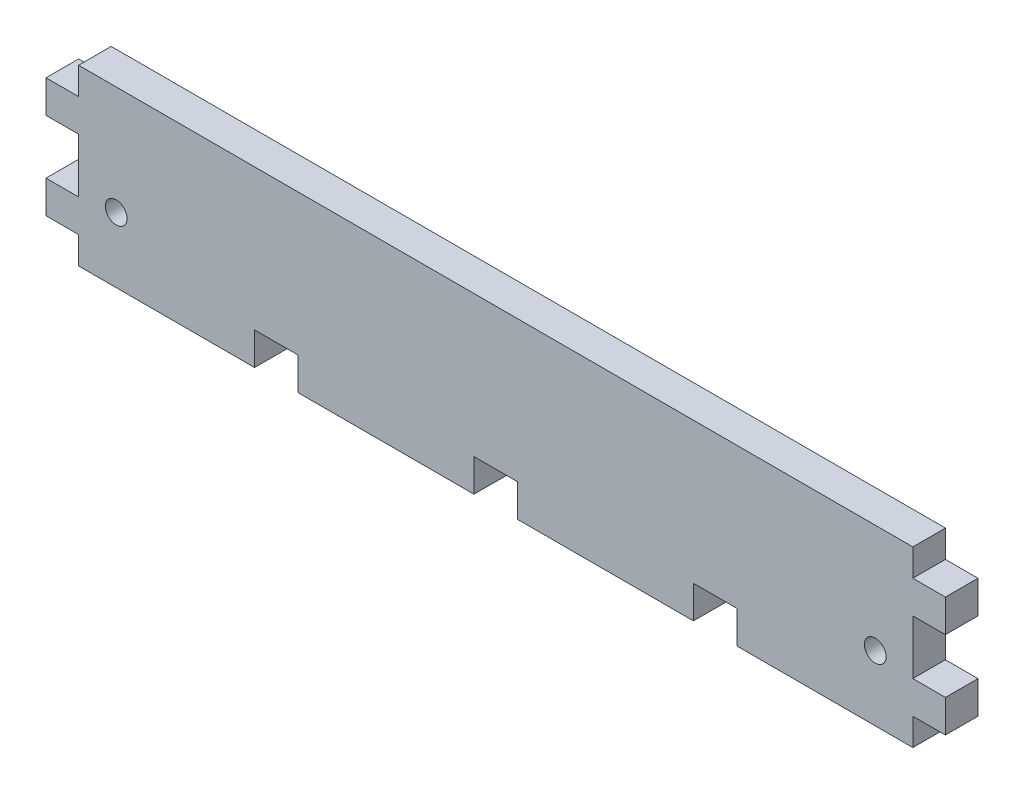
from build123d import *

# Parameters (mm, degrees)
SKETCH1_R           = 5
BOSS_EXTRUDE1_DEPTH = 15


with BuildPart() as part:
    # Sketch1 → Boss-Extrude1 (new body)
    with BuildSketch(Plane.XY):
        Polygon((0, 0), (0, 12.5), (-15, 12.5), (-15, 27.5), (0, 27.5), (0, 52.5), (-15, 52.5), (-15, 67.5), (0, 67.5), (0, 80), (384, 80), (384, 67.5), (399, 67.5), (399, 52.5), (384, 52.5), (384, 27.5), (399, 27.5), (399, 12.5), (384, 12.5), (384, 0), (303, 0), (303, 15), (283, 15), (283, 0), (202, 0), (202, 15), (182, 15), (182, 0), (101, 0), (101, 15), (81, 15), (81, 0), align=None)
        with Locations((17.3, 30)):
            Circle(SKETCH1_R, mode=Mode.SUBTRACT)
        with Locations(Location((366.7, 30, 0), (0, 0, 180))):  # turned: the seam where the file's is
            Circle(SKETCH1_R, mode=Mode.SUBTRACT)
    extrude(amount=BOSS_EXTRUDE1_DEPTH)


solid = part.part
